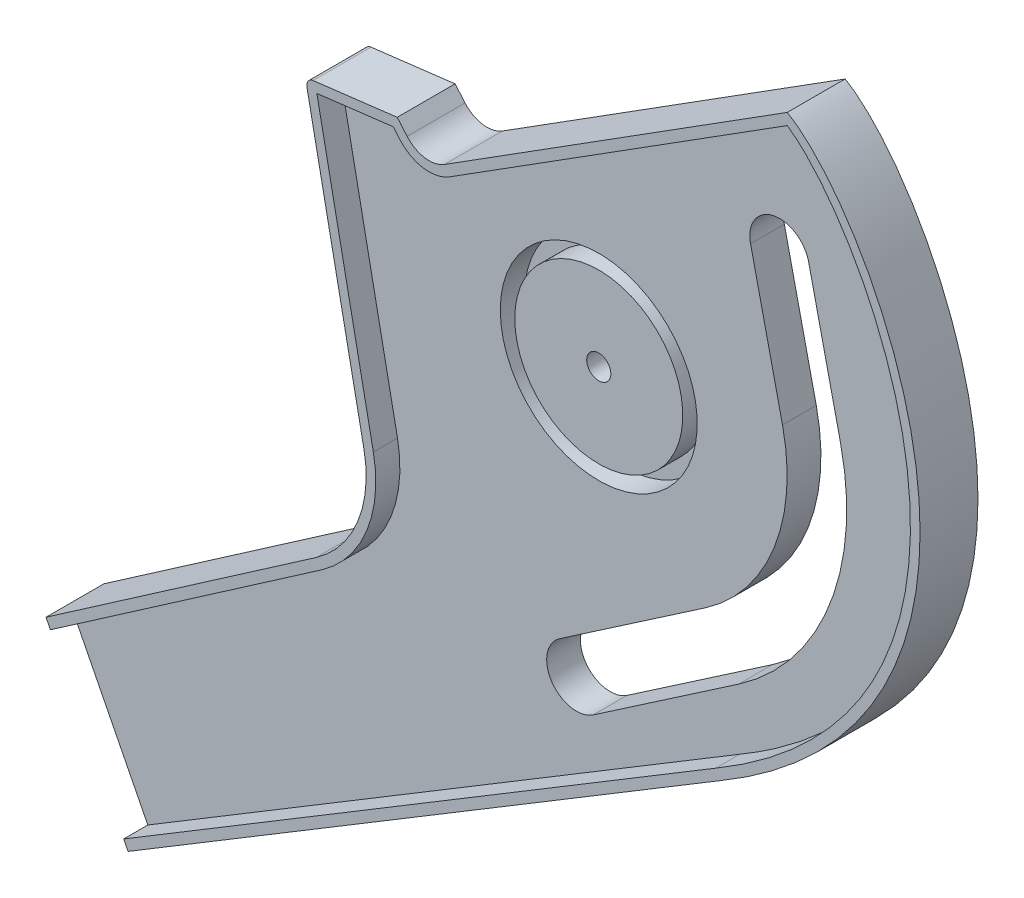
from build123d import *

# Parameters (mm, degrees)
SKETCH1_R           = 2.5
BOSS_EXTRUDE1_DEPTH = 12
CUT_EXTRUDE2_DEPTH  = 5
SKETCH2_R           = 20.406966807
SKETCH2_R_2         = 17.406966807
CUT_EXTRUDE1_DEPTH  = 5
SKETCH4_W           = 285.875648179
SKETCH4_H           = 19.682926892
CUT_EXTRUDE3_DEPTH  = 147.5


with BuildPart() as part:
    # Sketch1 → Boss-Extrude1 (new body)
    with BuildSketch(Plane.XY):
        with BuildLine():
            Line((-26.955627075, 25.359398414), (44.050751749, 70.198338512))
            add(Edge.make_bspline(
                [(44.050751749, 70.198338512), (62.087157858, 60.129124735), (102.236821697, -14.309839041), (30.255220871, -56.610877482)],
                knots=[0, 0, 0, 0, 1, 1, 1, 1], degree=3))
            Line((30.255220871, -56.610877482), (-92.542495842, -130.724182913))
            Line((-92.542495842, -130.724182913), (-109.546280871, -97.192243206))
            Line((-109.546280871, -97.192243206), (-53.551819625, -58.475967995))
            ThreePointArc((-53.551819625, -58.475967995), (-44.950344781, -47.729789478), (-43.667906214, -34.025006607))
            Line((-43.667906214, -34.025006607), (-55.484471769, 25.012678553))
            ThreePointArc((-55.484471769, 25.012678553), (-55.229156607, 26.186005417), (-54.194896814, 26.796077907))
            Line((-54.194896814, 26.796077907), (-36.765460017, 28.917713338))
            Line((-36.765460017, 28.917713338), (-34.712668517, 26.525380142))
            ThreePointArc((-34.712668517, 26.525380142), (-31.051074716, 24.4992182), (-26.955627075, 25.359398414))
        make_face()
        Circle(SKETCH1_R, mode=Mode.SUBTRACT)
        with BuildLine():
            Line((38.077539086, 8.627342387), (31.457970773, 37.843392922))
            ThreePointArc((31.457970773, 37.843392922), (36.113405951, 45.226418252), (43.49643128, 40.570983074))
            Line((43.49643128, 40.570983074), (50.115999593, 11.354932539))
            ThreePointArc((50.115999593, 11.354932539), (47.829544092, -18.785170217), (28.993629861, -42.425432651))
            Line((28.993629861, -42.425432651), (-1.139071825, -63.018184329))
            ThreePointArc((-1.139071825, -63.018184329), (-9.716926906, -61.404944758), (-8.103687335, -52.827089677))
            Line((-8.103687335, -52.827089677), (22.029014352, -32.234337999))
            ThreePointArc((22.029014352, -32.234337999), (36.340317452, -14.272748403), (38.077539086, 8.627342387))
        make_face(mode=Mode.SUBTRACT)
    boss_extrude1 = extrude(amount=-BOSS_EXTRUDE1_DEPTH)

    # Sketch3 → Cut-Extrude2 (cut)
    with BuildSketch(Plane(origin=(0, 0, -12), x_dir=(-1, 0, 0), z_dir=(0, 0, -1))):
        with BuildLine():
            Line((108.633361408, -98.992545924), (93.449492386, -128.935560359))
            Line((93.449492386, -128.935560359), (91.732523821, -127.89930155))
            Line((91.732523821, -127.89930155), (-29.231808811, -54.892516323))
            add(Edge.make_bspline(
                [(-44.065734477, 67.842412696), (-44.711989199, 67.409412256), (-45.319058391, 66.940521732), (-46.487121265, 65.960540056), (-47.04734625, 65.448744854), (-48.676831708, 63.866474713), (-49.695652132, 62.74980166), (-51.643061578, 60.433812481), (-52.570637695, 59.233568633), (-54.351661803, 56.76518688), (-55.206220539, 55.494184071), (-57.642169465, 51.637395526), (-59.108475151, 48.994377471), (-61.772216068, 43.585851359), (-62.968525898, 40.819830599), (-64.562191776, 36.579321004), (-65.059713989, 35.150465126), (-65.753925807, 32.983458962), (-65.976639631, 32.257164595), (-66.404295719, 30.796479627), (-66.609516748, 30.060994816), (-67.585549406, 26.379930292), (-68.207997329, 23.421535241), (-69.124162601, 17.476634327), (-69.417856055, 14.49012642), (-69.647875237, 8.486550939), (-69.584312973, 5.469492942), (-69.186185446, 0.918013899), (-69.001954276, -0.606436507), (-68.53395704, -3.614530288), (-68.249900615, -5.10403396), (-67.246805131, -9.528696616), (-66.377032654, -12.420063251), (-64.763908669, -16.667495261), (-64.174739481, -18.06835499), (-63.212508348, -20.146844678), (-62.87805617, -20.837039742), (-62.187699389, -22.200245629), (-61.831475952, -22.874060854), (-59.996492333, -26.20515645), (-58.3564207, -28.748698204), (-54.76187252, -33.614098874), (-52.807325031, -35.935907769), (-49.657387027, -39.264829798), (-48.576129174, -40.343226595), (-46.36681057, -42.431345516), (-45.23699415, -43.442927339), (-39.471767159, -48.350894333), (-34.491238963, -51.801735421), (-29.231808811, -54.892516323)],
                knots=[0, 0, 0, 0, 0.015625, 0.015625, 0.03125, 0.03125, 0.0625, 0.0625, 0.09375, 0.09375, 0.125, 0.125, 0.1875, 0.1875, 0.25, 0.25, 0.28125, 0.28125, 0.296875, 0.296875, 0.3125, 0.3125, 0.375, 0.375, 0.4375, 0.4375, 0.5, 0.5, 0.53125, 0.53125, 0.5625, 0.5625, 0.625, 0.625, 0.65625, 0.65625, 0.671875, 0.671875, 0.6875, 0.6875, 0.75, 0.75, 0.8125, 0.8125, 0.84375, 0.84375, 0.875, 0.875, 1, 1, 1, 1], degree=3))
            Line((-44.065734477, 67.842412696), (25.887763568, 23.668343261))
            ThreePointArc((25.887763568, 23.668343261), (31.348360423, 22.521436309), (36.230485491, 25.222985565))
            Line((36.230485491, 25.222985565), (37.586279366, 26.80303434))
            Line((37.586279366, 26.80303434), (53.417437888, 24.875952746))
            Line((53.417437888, 24.875952746), (41.706802558, -33.632485968))
            ThreePointArc((41.706802558, -33.632485968), (43.096111006, -48.479334078), (52.414375421, -60.121027471))
            Line((52.414375421, -60.121027471), (106.973050581, -97.844556472))
            Line((106.973050581, -97.844556472), (108.633361408, -98.992545924))
        make_face()
    cut_extrude2 = extrude(amount=-CUT_EXTRUDE2_DEPTH, mode=Mode.SUBTRACT)

    # Sketch2 → Cut-Extrude1 (cut)
    with BuildSketch(Plane(origin=(0, 0, -7), x_dir=(-1, 0, 0), z_dir=(0, 0, -1))):
        Circle(SKETCH2_R)
        Circle(SKETCH2_R_2, mode=Mode.SUBTRACT)
    cut_extrude1 = extrude(amount=-CUT_EXTRUDE1_DEPTH, mode=Mode.SUBTRACT)

    # Mirror2: Boss-Extrude1, Cut-Extrude2, Cut-Extrude1 across plane
    add(boss_extrude1.mirror(Plane.XY))
    add(cut_extrude2.mirror(Plane.XY), mode=Mode.SUBTRACT)
    add(cut_extrude1.mirror(Plane.XY), mode=Mode.SUBTRACT)

    # Sketch4 → Cut-Extrude3 (cut, symmetric)
    with BuildSketch(Plane(origin=(0, 0, 0), x_dir=(1, 0, 0), z_dir=(0, 1, 0))):
        with Locations((-41.859921239, 9.841463446)):
            Rectangle(SKETCH4_W, SKETCH4_H)
    extrude(amount=CUT_EXTRUDE3_DEPTH, both=True, mode=Mode.SUBTRACT)


solid = part.part
